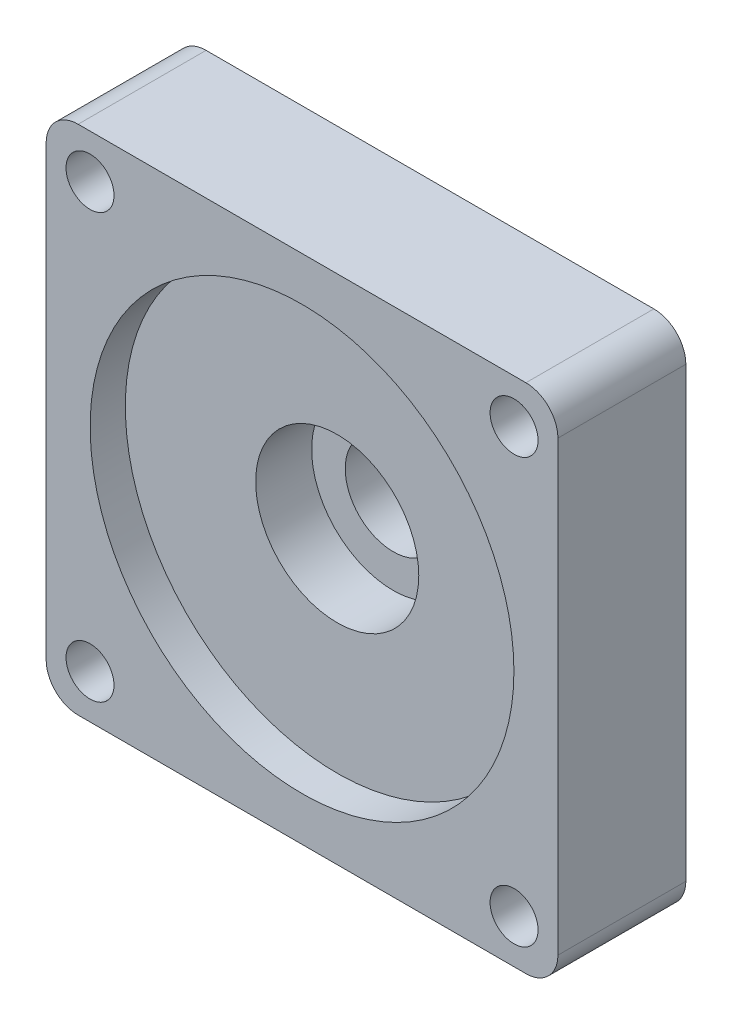
from build123d import *

# Parameters (mm, degrees)
SKETCH_1_W          = 32
SKETCH_1_H          = 32
EXTRUDE_1_DEPTH     = 8
CUT_EXTRUDE_1_REACH = 10
SKETCH_2_R          = 1.5
SKETCH_3_R          = 13.25
CUT_EXTRUDE_2_DEPTH = 2.2
SKETCH_4_R          = 5.1
CUT_EXTRUDE_3_DEPTH = 3.5
CUT_EXTRUDE_4_REACH = 4.3
SKETCH_5_R          = 3
FILLET_1_R          = 2


with BuildPart() as part:
    # 草图1 → 凸台-拉伸1 (new body)
    with BuildSketch(Plane.XY):
        Rectangle(SKETCH_1_W, SKETCH_1_H)
    extrude(amount=EXTRUDE_1_DEPTH)

    # 草图2 → 切除-拉伸1 (cut, up to next)
    with BuildSketch(Plane.XY.offset(8), mode=Mode.PRIVATE) as cut_extrude_1_sk1:
        with Locations((-13.258252147, 13.258252147)):
            Circle(SKETCH_2_R)
    cut_extrude_1_tool1 = extrude(cut_extrude_1_sk1.sketch, amount=-CUT_EXTRUDE_1_REACH, mode=Mode.PRIVATE) & part.part
    add(cut_extrude_1_tool1.solids().sort_by_distance((-13.258252, 13.258252, 8))[0], mode=Mode.SUBTRACT)
    # 草图2 → 切除-拉伸1 (cut, up to next)
    with BuildSketch(Plane.XY.offset(8), mode=Mode.PRIVATE) as cut_extrude_1_sk2:
        with Locations((13.258252147, 13.258252147)):
            Circle(SKETCH_2_R)
    cut_extrude_1_tool2 = extrude(cut_extrude_1_sk2.sketch, amount=-CUT_EXTRUDE_1_REACH, mode=Mode.PRIVATE) & part.part
    add(cut_extrude_1_tool2.solids().sort_by_distance((13.258252, 13.258252, 8))[0], mode=Mode.SUBTRACT)
    # 草图2 → 切除-拉伸1 (cut, up to next)
    with BuildSketch(Plane.XY.offset(8), mode=Mode.PRIVATE) as cut_extrude_1_sk3:
        with Locations((13.258252147, -13.258252147)):
            Circle(SKETCH_2_R)
    cut_extrude_1_tool3 = extrude(cut_extrude_1_sk3.sketch, amount=-CUT_EXTRUDE_1_REACH, mode=Mode.PRIVATE) & part.part
    add(cut_extrude_1_tool3.solids().sort_by_distance((13.258252, -13.258252, 8))[0], mode=Mode.SUBTRACT)
    # 草图2 → 切除-拉伸1 (cut, up to next)
    with BuildSketch(Plane.XY.offset(8), mode=Mode.PRIVATE) as cut_extrude_1_sk4:
        with Locations((-13.258252147, -13.258252147)):
            Circle(SKETCH_2_R)
    cut_extrude_1_tool4 = extrude(cut_extrude_1_sk4.sketch, amount=-CUT_EXTRUDE_1_REACH, mode=Mode.PRIVATE) & part.part
    add(cut_extrude_1_tool4.solids().sort_by_distance((-13.258252, -13.258252, 8))[0], mode=Mode.SUBTRACT)

    # 草图3 → 切除-拉伸2 (cut)
    with BuildSketch(Plane.XY.offset(8)):
        Circle(SKETCH_3_R)
    extrude(amount=-CUT_EXTRUDE_2_DEPTH, mode=Mode.SUBTRACT)

    # 草图4 → 切除-拉伸3 (cut)
    with BuildSketch(Plane.XY.offset(5.8)):
        Circle(SKETCH_4_R)
    extrude(amount=-CUT_EXTRUDE_3_DEPTH, mode=Mode.SUBTRACT)

    # 草图5 → 切除-拉伸4 (cut, up to next)
    with BuildSketch(Plane.XY.offset(2.3), mode=Mode.PRIVATE) as cut_extrude_4_sk1:
        Circle(SKETCH_5_R)
    cut_extrude_4_tool1 = extrude(cut_extrude_4_sk1.sketch, amount=-CUT_EXTRUDE_4_REACH, mode=Mode.PRIVATE) & part.part
    add(cut_extrude_4_tool1.solids().sort_by_distance((0, 0, 2.3))[0], mode=Mode.SUBTRACT)

    # 圆角1
    fillet_1_edges = [part.edges().sort_by_distance(p)[0] for p in [
        (16, -16, 4),
        (-16, -16, 4),
        (-16, 16, 4),
        (16, 16, 4),
    ]]
    fillet(fillet_1_edges, radius=FILLET_1_R)


solid = part.part
